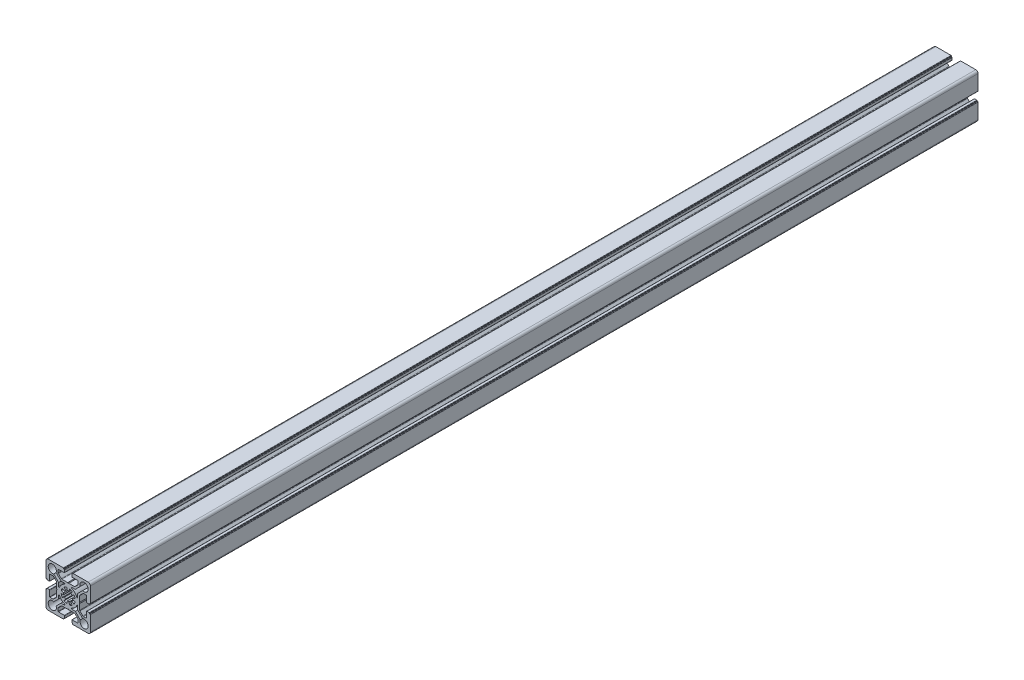
from build123d import *

# Parameters (mm, degrees)
EXTRUDE_2_DEPTH = 1000


with BuildPart() as part:
    # Эскиз2 → Бобышка-Вытянуть2 (new body)
    with BuildSketch(Plane.XY):
        with BuildLine():
            Line((-25, 11.3), (-25, 22.5))
            ThreePointArc((-25, 22.5), (-24.267766953, 24.267766953), (-22.5, 25))
            Line((-22.5, 25), (-11.3, 25))
            Line((-11.3, 25), (-5.4, 25))
            ThreePointArc((-5.4, 25), (-5.187867966, 24.912132034), (-5.1, 24.7))
            Line((-5.1, 24.7), (-5.1, 24))
            Line((-5.1, 24), (-4.4, 24))
            ThreePointArc((-4.4, 24), (-4.187867966, 23.912132034), (-4.1, 23.7))
            Line((-4.1, 23.7), (-4.1, 21.1))
            ThreePointArc((-4.1, 21.1), (-4.187867966, 20.887867966), (-4.4, 20.8))
            Line((-4.4, 20.8), (-11, 20.8))
            ThreePointArc((-11, 20.8), (-11.212132034, 20.712132034), (-11.3, 20.5))
            Line((-11.3, 20.5), (-11.3, 17.214213562))
            ThreePointArc((-11.3, 17.214213562), (-11.223879533, 16.83153013), (-11.007106781, 16.507106781))
            Line((-11.007106781, 16.507106781), (-7.792893219, 13.292893219))
            ThreePointArc((-7.792893219, 13.292893219), (-7.46846987, 13.076120467), (-7.085786438, 13))
            Line((-7.085786438, 13), (-0.6, 13))
            Line((-0.6, 13), (0, 12.4))
            Line((0, 12.4), (0.6, 13))
            Line((0.6, 13), (7.085786438, 13))
            ThreePointArc((7.085786438, 13), (7.46846987, 13.076120467), (7.792893219, 13.292893219))
            Line((7.792893219, 13.292893219), (11.007106781, 16.507106781))
            ThreePointArc((11.007106781, 16.507106781), (11.223879533, 16.83153013), (11.3, 17.214213562))
            Line((11.3, 17.214213562), (11.3, 20.5))
            ThreePointArc((11.3, 20.5), (11.212132034, 20.712132034), (11, 20.8))
            Line((11, 20.8), (4.4, 20.8))
            ThreePointArc((4.4, 20.8), (4.187867966, 20.887867966), (4.1, 21.1))
            Line((4.1, 21.1), (4.1, 23.7))
            ThreePointArc((4.1, 23.7), (4.187867966, 23.912132034), (4.4, 24))
            Line((4.4, 24), (5.1, 24))
            Line((5.1, 24), (5.1, 24.7))
            ThreePointArc((5.1, 24.7), (5.187867966, 24.912132034), (5.4, 25))
            Line((5.4, 25), (11.3, 25))
            Line((11.3, 25), (22.5, 25))
            ThreePointArc((22.5, 25), (24.267766953, 24.267766953), (25, 22.5))
            Line((25, 22.5), (25, 11.3))
            Line((25, 11.3), (25, 5.4))
            ThreePointArc((25, 5.4), (24.912132034, 5.187867966), (24.7, 5.1))
            Line((24.7, 5.1), (24, 5.1))
            Line((24, 5.1), (24, 4.4))
            ThreePointArc((24, 4.4), (23.912132034, 4.187867966), (23.7, 4.1))
            Line((23.7, 4.1), (21.1, 4.1))
            ThreePointArc((21.1, 4.1), (20.887867966, 4.187867966), (20.8, 4.4))
            Line((20.8, 4.4), (20.8, 11))
            ThreePointArc((20.8, 11), (20.712132034, 11.212132034), (20.5, 11.3))
            Line((20.5, 11.3), (17.214213562, 11.3))
            ThreePointArc((17.214213562, 11.3), (16.83153013, 11.223879533), (16.507106781, 11.007106781))
            Line((16.507106781, 11.007106781), (13.292893219, 7.792893219))
            ThreePointArc((13.292893219, 7.792893219), (13.076120467, 7.46846987), (13, 7.085786438))
            Line((13, 7.085786438), (13, 0.6))
            Line((13, 0.6), (12.4, 0))
            Line((12.4, 0), (13, -0.6))
            Line((13, -0.6), (13, -7.085786438))
            ThreePointArc((13, -7.085786438), (13.076120467, -7.46846987), (13.292893219, -7.792893219))
            Line((13.292893219, -7.792893219), (16.507106781, -11.007106781))
            ThreePointArc((16.507106781, -11.007106781), (16.83153013, -11.223879533), (17.214213562, -11.3))
            Line((17.214213562, -11.3), (20.5, -11.3))
            ThreePointArc((20.5, -11.3), (20.712132034, -11.212132034), (20.8, -11))
            Line((20.8, -11), (20.8, -4.4))
            ThreePointArc((20.8, -4.4), (20.887867966, -4.187867966), (21.1, -4.1))
            Line((21.1, -4.1), (23.7, -4.1))
            ThreePointArc((23.7, -4.1), (23.912132034, -4.187867966), (24, -4.4))
            Line((24, -4.4), (24, -5.1))
            Line((24, -5.1), (24.7, -5.1))
            ThreePointArc((24.7, -5.1), (24.912132034, -5.187867966), (25, -5.4))
            Line((25, -5.4), (25, -11.3))
            Line((25, -11.3), (25, -22.5))
            ThreePointArc((25, -22.5), (24.267766953, -24.267766953), (22.5, -25))
            Line((22.5, -25), (11.3, -25))
            Line((11.3, -25), (5.4, -25))
            ThreePointArc((5.4, -25), (5.187867966, -24.912132034), (5.1, -24.7))
            Line((5.1, -24.7), (5.1, -24))
            Line((5.1, -24), (4.4, -24))
            ThreePointArc((4.4, -24), (4.187867966, -23.912132034), (4.1, -23.7))
            Line((4.1, -23.7), (4.1, -21.1))
            ThreePointArc((4.1, -21.1), (4.187867966, -20.887867966), (4.4, -20.8))
            Line((4.4, -20.8), (11, -20.8))
            ThreePointArc((11, -20.8), (11.212132034, -20.712132034), (11.3, -20.5))
            Line((11.3, -20.5), (11.3, -17.214213562))
            ThreePointArc((11.3, -17.214213562), (11.223879533, -16.83153013), (11.007106781, -16.507106781))
            Line((11.007106781, -16.507106781), (7.792893219, -13.292893219))
            ThreePointArc((7.792893219, -13.292893219), (7.46846987, -13.076120467), (7.085786438, -13))
            Line((7.085786438, -13), (0.6, -13))
            Line((0.6, -13), (0, -12.4))
            Line((0, -12.4), (-0.6, -13))
            Line((-0.6, -13), (-7.085786438, -13))
            ThreePointArc((-7.085786438, -13), (-7.46846987, -13.076120467), (-7.792893219, -13.292893219))
            Line((-7.792893219, -13.292893219), (-11.007106781, -16.507106781))
            ThreePointArc((-11.007106781, -16.507106781), (-11.223879533, -16.83153013), (-11.3, -17.214213562))
            Line((-11.3, -17.214213562), (-11.3, -20.5))
            ThreePointArc((-11.3, -20.5), (-11.212132034, -20.712132034), (-11, -20.8))
            Line((-11, -20.8), (-4.4, -20.8))
            ThreePointArc((-4.4, -20.8), (-4.187867966, -20.887867966), (-4.1, -21.1))
            Line((-4.1, -21.1), (-4.1, -23.7))
            ThreePointArc((-4.1, -23.7), (-4.187867966, -23.912132034), (-4.4, -24))
            Line((-4.4, -24), (-5.1, -24))
            Line((-5.1, -24), (-5.1, -24.7))
            ThreePointArc((-5.1, -24.7), (-5.187867966, -24.912132034), (-5.4, -25))
            Line((-5.4, -25), (-11.3, -25))
            Line((-11.3, -25), (-22.5, -25))
            ThreePointArc((-22.5, -25), (-24.267766953, -24.267766953), (-25, -22.5))
            Line((-25, -22.5), (-25, -11.3))
            Line((-25, -11.3), (-25, -5.4))
            ThreePointArc((-25, -5.4), (-24.912132034, -5.187867966), (-24.7, -5.1))
            Line((-24.7, -5.1), (-24, -5.1))
            Line((-24, -5.1), (-24, -4.4))
            ThreePointArc((-24, -4.4), (-23.912132034, -4.187867966), (-23.7, -4.1))
            Line((-23.7, -4.1), (-21.1, -4.1))
            ThreePointArc((-21.1, -4.1), (-20.887867966, -4.187867966), (-20.8, -4.4))
            Line((-20.8, -4.4), (-20.8, -11))
            ThreePointArc((-20.8, -11), (-20.712132034, -11.212132034), (-20.5, -11.3))
            Line((-20.5, -11.3), (-17.214213562, -11.3))
            ThreePointArc((-17.214213562, -11.3), (-16.83153013, -11.223879533), (-16.507106781, -11.007106781))
            Line((-16.507106781, -11.007106781), (-13.292893219, -7.792893219))
            ThreePointArc((-13.292893219, -7.792893219), (-13.076120467, -7.46846987), (-13, -7.085786438))
            Line((-13, -7.085786438), (-13, -0.6))
            Line((-13, -0.6), (-12.4, 0))
            Line((-12.4, 0), (-13, 0.6))
            Line((-13, 0.6), (-13, 7.085786438))
            ThreePointArc((-13, 7.085786438), (-13.076120467, 7.46846987), (-13.292893219, 7.792893219))
            Line((-13.292893219, 7.792893219), (-16.507106781, 11.007106781))
            ThreePointArc((-16.507106781, 11.007106781), (-16.83153013, 11.223879533), (-17.214213562, 11.3))
            Line((-17.214213562, 11.3), (-20.5, 11.3))
            ThreePointArc((-20.5, 11.3), (-20.712132034, 11.212132034), (-20.8, 11))
            Line((-20.8, 11), (-20.8, 4.4))
            ThreePointArc((-20.8, 4.4), (-20.887867966, 4.187867966), (-21.1, 4.1))
            Line((-21.1, 4.1), (-23.7, 4.1))
            ThreePointArc((-23.7, 4.1), (-23.912132034, 4.187867966), (-24, 4.4))
            Line((-24, 4.4), (-24, 5.1))
            Line((-24, 5.1), (-24.7, 5.1))
            ThreePointArc((-24.7, 5.1), (-24.912132034, 5.187867966), (-25, 5.4))
            Line((-25, 5.4), (-25, 11.3))
        make_face()
        with BuildLine():
            Line((-10.7, 8.012994231), (-10.7, 4.118252056))
            ThreePointArc((-10.7, 4.118252056), (-10.295346259, 3.627427148), (-9.736363636, 3.931058781))
            ThreePointArc((-9.736363636, 3.931058781), (-7.424621202, 7.424621202), (-3.931058781, 9.736363636))
            ThreePointArc((-3.931058781, 9.736363636), (-3.627427148, 10.295346259), (-4.118252056, 10.7))
            Line((-4.118252056, 10.7), (-8.012994231, 10.7))
            Line((-8.012994231, 10.7), (-13.594234467, 16.281240236))
            ThreePointArc((-13.594234467, 16.281240236), (-21.152691193, 21.152691193), (-16.281240236, 13.594234467))
            Line((-16.281240236, 13.594234467), (-10.7, 8.012994231))
        make_face(mode=Mode.SUBTRACT)
        with BuildLine():
            Line((10.7, 8.012994231), (16.281240236, 13.594234467))
            ThreePointArc((16.281240236, 13.594234467), (21.152691193, 21.152691193), (13.594234467, 16.281240236))
            Line((13.594234467, 16.281240236), (8.012994231, 10.7))
            Line((8.012994231, 10.7), (4.118252056, 10.7))
            ThreePointArc((4.118252056, 10.7), (3.627427148, 10.295346259), (3.931058781, 9.736363636))
            ThreePointArc((3.931058781, 9.736363636), (7.424621202, 7.424621202), (9.736363636, 3.931058781))
            ThreePointArc((9.736363636, 3.931058781), (10.295346259, 3.627427148), (10.7, 4.118252056))
            Line((10.7, 4.118252056), (10.7, 8.012994231))
        make_face(mode=Mode.SUBTRACT)
        with BuildLine():
            Line((8.012994231, -10.7), (13.594234467, -16.281240236))
            ThreePointArc((13.594234467, -16.281240236), (21.152691193, -21.152691193), (16.281240236, -13.594234467))
            Line((16.281240236, -13.594234467), (10.7, -8.012994231))
            Line((10.7, -8.012994231), (10.7, -4.118252056))
            ThreePointArc((10.7, -4.118252056), (10.295346259, -3.627427148), (9.736363636, -3.931058781))
            ThreePointArc((9.736363636, -3.931058781), (7.424621202, -7.424621202), (3.931058781, -9.736363636))
            ThreePointArc((3.931058781, -9.736363636), (3.627427148, -10.295346259), (4.118252056, -10.7))
            Line((4.118252056, -10.7), (8.012994231, -10.7))
        make_face(mode=Mode.SUBTRACT)
        with BuildLine():
            Line((-10.7, -8.012994231), (-16.281240236, -13.594234467))
            ThreePointArc((-16.281240236, -13.594234467), (-21.152691193, -21.152691193), (-13.594234467, -16.281240236))
            Line((-13.594234467, -16.281240236), (-8.012994231, -10.7))
            Line((-8.012994231, -10.7), (-4.118252056, -10.7))
            ThreePointArc((-4.118252056, -10.7), (-3.627427148, -10.295346259), (-3.931058781, -9.736363636))
            ThreePointArc((-3.931058781, -9.736363636), (-7.424621202, -7.424621202), (-9.736363636, -3.931058781))
            ThreePointArc((-9.736363636, -3.931058781), (-10.295346259, -3.627427148), (-10.7, -4.118252056))
            Line((-10.7, -4.118252056), (-10.7, -8.012994231))
        make_face(mode=Mode.SUBTRACT)
        with BuildLine():
            Line((1.457884204, 7.866039261), (0.92940118, 5.014600029))
            ThreePointArc((0.92940118, 5.014600029), (0, 5.1), (-0.92940118, 5.014600029))
            Line((-0.92940118, 5.014600029), (-1.457884204, 7.866039261))
            ThreePointArc((-1.457884204, 7.866039261), (-3.061467459, 7.39103626), (-4.531249895, 6.593009509))
            Line((-4.531249895, 6.593009509), (-2.888671808, 4.203043562))
            ThreePointArc((-2.888671808, 4.203043562), (-3.606244584, 3.606244584), (-4.203043562, 2.888671808))
            Line((-4.203043562, 2.888671808), (-6.593009509, 4.531249895))
            ThreePointArc((-6.593009509, 4.531249895), (-7.39103626, 3.061467459), (-7.866039261, 1.457884204))
            Line((-7.866039261, 1.457884204), (-5.014600029, 0.92940118))
            ThreePointArc((-5.014600029, 0.92940118), (-5.1, 0), (-5.014600029, -0.92940118))
            Line((-5.014600029, -0.92940118), (-7.866039261, -1.457884204))
            ThreePointArc((-7.866039261, -1.457884204), (-7.39103626, -3.061467459), (-6.593009509, -4.531249895))
            Line((-6.593009509, -4.531249895), (-4.203043562, -2.888671808))
            ThreePointArc((-4.203043562, -2.888671808), (-3.606244584, -3.606244584), (-2.888671808, -4.203043562))
            Line((-2.888671808, -4.203043562), (-4.531249895, -6.593009509))
            ThreePointArc((-4.531249895, -6.593009509), (-3.061467459, -7.39103626), (-1.457884204, -7.866039261))
            Line((-1.457884204, -7.866039261), (-0.92940118, -5.014600029))
            ThreePointArc((-0.92940118, -5.014600029), (0, -5.1), (0.92940118, -5.014600029))
            Line((0.92940118, -5.014600029), (1.457884204, -7.866039261))
            ThreePointArc((1.457884204, -7.866039261), (3.061467459, -7.39103626), (4.531249895, -6.593009509))
            Line((4.531249895, -6.593009509), (2.888671808, -4.203043562))
            ThreePointArc((2.888671808, -4.203043562), (3.606244584, -3.606244584), (4.203043562, -2.888671808))
            Line((4.203043562, -2.888671808), (6.593009509, -4.531249895))
            ThreePointArc((6.593009509, -4.531249895), (7.39103626, -3.061467459), (7.866039261, -1.457884204))
            Line((7.866039261, -1.457884204), (5.014600029, -0.92940118))
            ThreePointArc((5.014600029, -0.92940118), (5.1, 0), (5.014600029, 0.92940118))
            Line((5.014600029, 0.92940118), (7.866039261, 1.457884204))
            ThreePointArc((7.866039261, 1.457884204), (7.39103626, 3.061467459), (6.593009509, 4.531249895))
            Line((6.593009509, 4.531249895), (4.203043562, 2.888671808))
            ThreePointArc((4.203043562, 2.888671808), (3.606244584, 3.606244584), (2.888671808, 4.203043562))
            Line((2.888671808, 4.203043562), (4.531249895, 6.593009509))
            ThreePointArc((4.531249895, 6.593009509), (3.061467459, 7.39103626), (1.457884204, 7.866039261))
        make_face(mode=Mode.SUBTRACT)
    extrude(amount=EXTRUDE_2_DEPTH)


solid = part.part
